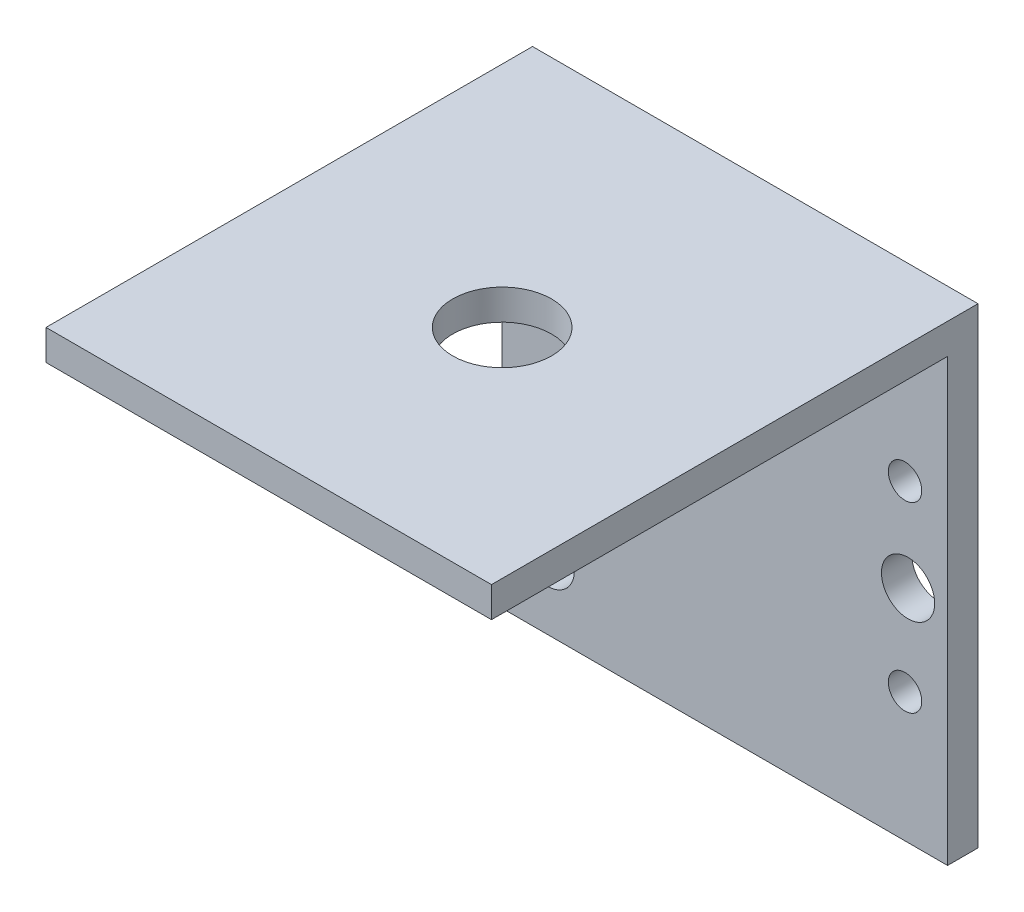
from build123d import *

# Parameters (mm, degrees)
SKETCH_1_W           = 29.3
SKETCH_1_H           = 29
EXTRUDE_1_DEPTH      = 2
SKETCH_2_R           = 1.75
CUT_EXTRUDE_1_DEPTH  = 2
SKETCH_3_R           = 1.1
CUT_EXTRUDE_2_DEPTH  = 2
SKETCH_4_W           = 29.3
SKETCH_4_H           = 2
EXTRUDE_2_DEPTH      = 30
EXTRUDE_2_DEPTH_BACK = 2
SKETCH_5_R           = 3.25
CUT_EXTRUDE_3_DEPTH  = 30


with BuildPart() as part:
    # 草图1 → 凸台-拉伸1 (new body)
    with BuildSketch(Plane.XY):
        Rectangle(SKETCH_1_W, SKETCH_1_H)
    extrude(amount=EXTRUDE_1_DEPTH)

    # 草图2 → 切除-拉伸1 (cut)
    with BuildSketch(Plane.XY.offset(2)):
        with Locations((-11.65, 10)):
            Circle(SKETCH_2_R)
        with Locations((-11.65, -10)):
            Circle(SKETCH_2_R)
        with Locations((12.05, 0)):
            Circle(SKETCH_2_R)
    extrude(amount=-CUT_EXTRUDE_1_DEPTH, mode=Mode.SUBTRACT)

    # 草图3 → 切除-拉伸2 (cut)
    with BuildSketch(Plane.XY.offset(2)):
        with Locations((-10.15, 5.995187484)):
            Circle(SKETCH_3_R)
        with Locations((-10.15, -6.004812516)):
            Circle(SKETCH_3_R)
        with Locations((11.85, 5.995187484)):
            Circle(SKETCH_3_R)
        with Locations((11.85, -6.004812516)):
            Circle(SKETCH_3_R)
    extrude(amount=-CUT_EXTRUDE_2_DEPTH, mode=Mode.SUBTRACT)

    # 草图4 → 凸台-拉伸2 (add, two sides)
    with BuildSketch(Plane.XY.offset(2)) as extrude_2_sk:
        with Locations((0, 15.5)):
            Rectangle(SKETCH_4_W, SKETCH_4_H)
    extrude(amount=EXTRUDE_2_DEPTH)
    extrude(extrude_2_sk.sketch, amount=-EXTRUDE_2_DEPTH_BACK)

    # 草图5 → 切除-拉伸3 (cut)
    with BuildSketch(Plane.XZ.offset(-14.5)):
        with Locations((0.35, 17)):
            Circle(SKETCH_5_R)
    extrude(amount=-CUT_EXTRUDE_3_DEPTH, mode=Mode.SUBTRACT)


solid = part.part
